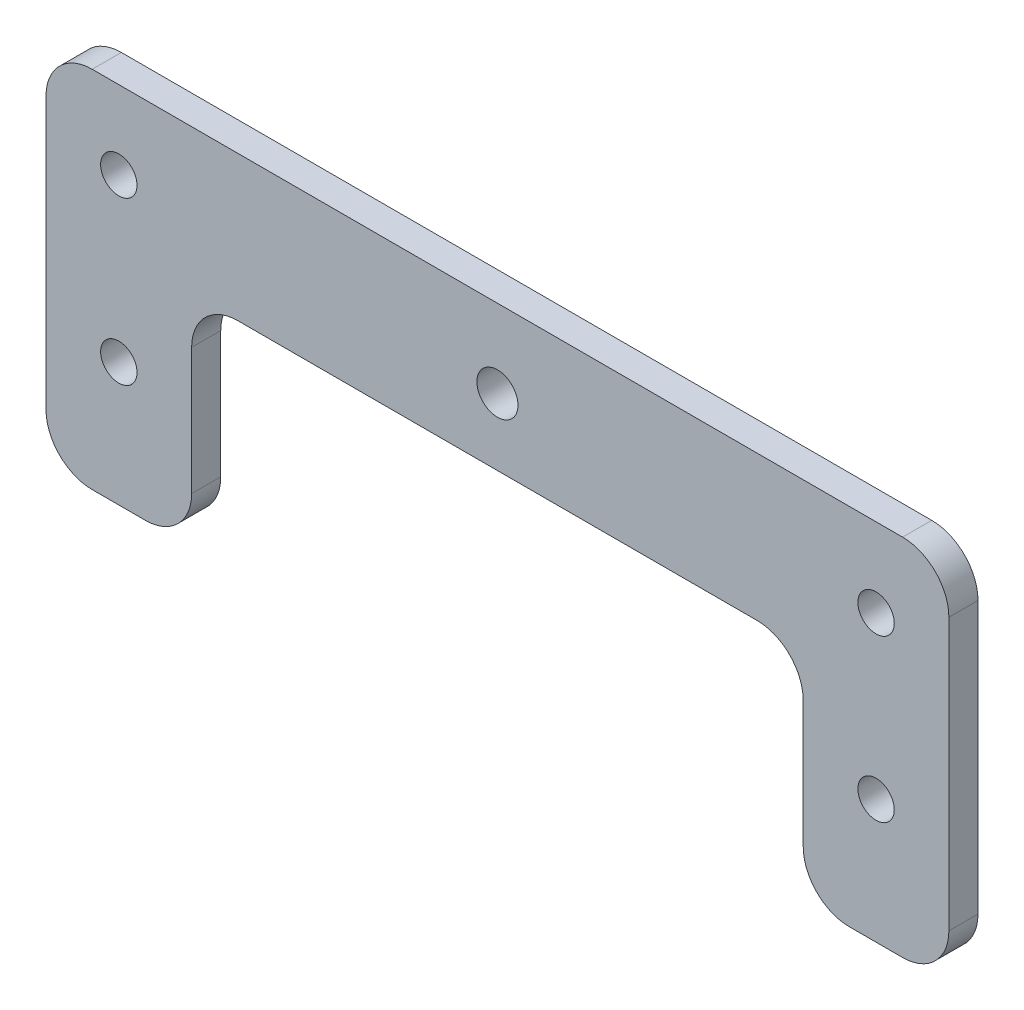
from build123d import *

# Parameters (mm, degrees)
CROQUIS1_R              = 2.5
CROQUIS1_R_2            = 2.821368504
SALIENTE_EXTRUIR1_DEPTH = 4


with BuildPart() as part:
    # Croquis1 → Saliente-Extruir1 (new body)
    with BuildSketch(Plane.XY):
        with BuildLine():
            Line((26.538050923, 6.699416954), (97.838050923, 6.699416954))
            ThreePointArc((97.838050923, 6.699416954), (102.328178983, 4.839545014), (104.188050923, 0.349416954))
            Line((104.188050923, 0.349416954), (104.188050923, -17.045643676))
            ThreePointArc((104.188050923, -17.045643676), (106.047922862, -21.535771736), (110.538050923, -23.395643676))
            Line((110.538050923, -23.395643676), (117.838050923, -23.395643676))
            ThreePointArc((117.838050923, -23.395643676), (122.328178983, -21.535771736), (124.188050923, -17.045643676))
            Line((124.188050923, -17.045643676), (124.188050923, 6.604356324))
            Line((124.188050923, 6.604356324), (124.188050923, 20.254356324))
            ThreePointArc((124.188050923, 20.254356324), (122.328178983, 24.744484385), (117.838050923, 26.604356324))
            Line((117.838050923, 26.604356324), (6.538050923, 26.604356324))
            ThreePointArc((6.538050923, 26.604356324), (2.047922862, 24.744484385), (0.188050923, 20.254356324))
            Line((0.188050923, 20.254356324), (0.188050923, 6.604356324))
            Line((0.188050923, 6.604356324), (0.188050923, -17.045643676))
            ThreePointArc((0.188050923, -17.045643676), (2.047922862, -21.535771736), (6.538050923, -23.395643676))
            Line((6.538050923, -23.395643676), (13.838050923, -23.395643676))
            ThreePointArc((13.838050923, -23.395643676), (18.328178983, -21.535771736), (20.188050923, -17.045643676))
            Line((20.188050923, -17.045643676), (20.188050923, 0.349416954))
            ThreePointArc((20.188050923, 0.349416954), (22.047922862, 4.839545014), (26.538050923, 6.699416954))
        make_face()
        with Locations((10.188050923, 15.866498333)):
            Circle(CROQUIS1_R, mode=Mode.SUBTRACT)
        with Locations((114.188050923, 15.771437703)):
            Circle(CROQUIS1_R, mode=Mode.SUBTRACT)
        with Locations((10.188050923, -6.395643676)):
            Circle(CROQUIS1_R, mode=Mode.SUBTRACT)
        with Locations((62.188050923, 15.866498333)):
            Circle(CROQUIS1_R_2, mode=Mode.SUBTRACT)
        with Locations((114.188050923, -6.395643676)):
            Circle(CROQUIS1_R, mode=Mode.SUBTRACT)
    extrude(amount=SALIENTE_EXTRUIR1_DEPTH)


solid = part.part
